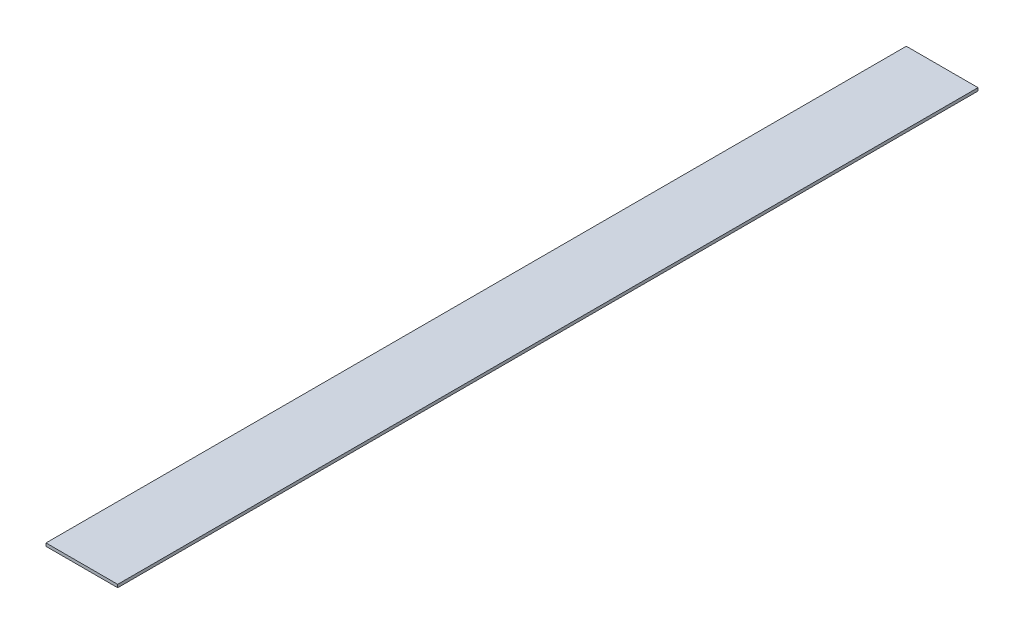
from build123d import *

# Parameters (mm, degrees)
SKETCH1_W           = 76.2
SKETCH1_H           = 914.4
BOSS_EXTRUDE1_DEPTH = 3.175


with BuildPart() as part:
    # Sketch1 → Boss-Extrude1 (new body)
    with BuildSketch(Plane(origin=(0, 0, 0), x_dir=(1, 0, 0), z_dir=(0, 1, 0))):
        with Locations((38.1, 457.2)):
            Rectangle(SKETCH1_W, SKETCH1_H)
    extrude(amount=BOSS_EXTRUDE1_DEPTH)


solid = part.part
